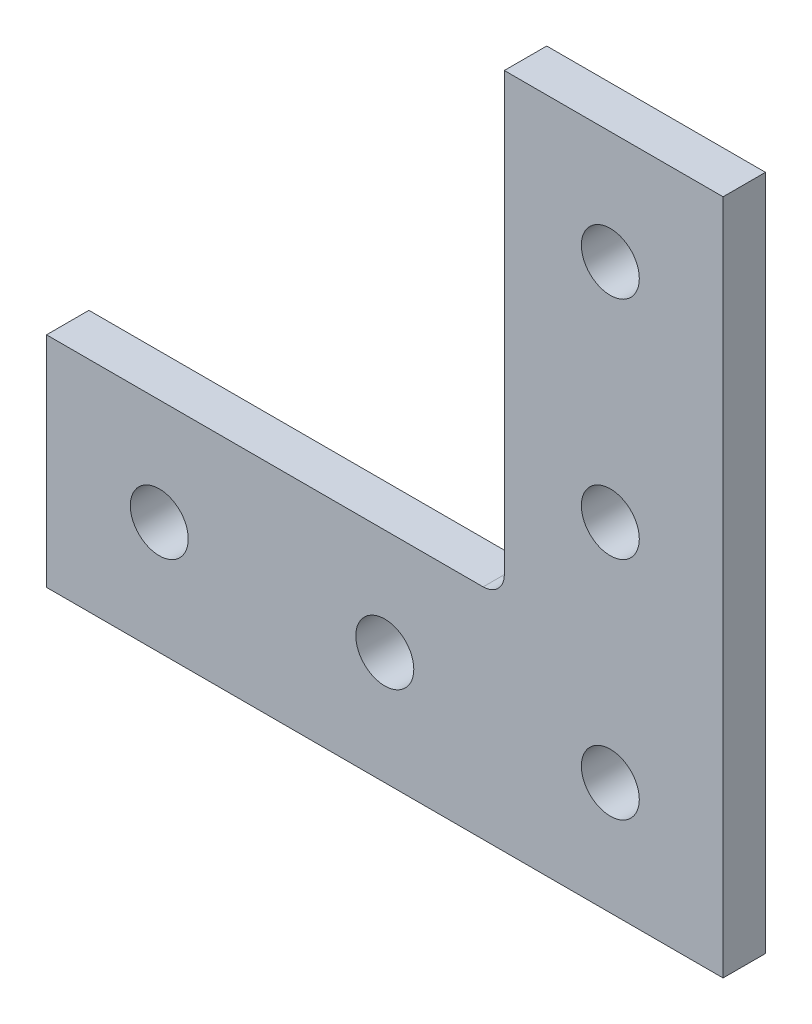
from build123d import *

# Parameters (mm, degrees)
SKETCH1_R           = 3.2639
BOSS_EXTRUDE1_DEPTH = 4.7752


with BuildPart() as part:
    # Sketch1 → Boss-Extrude1 (new body)
    with BuildSketch(Plane.XY):
        with BuildLine():
            Line((-76.2, 0), (0, 0))
            Line((0, 0), (0, 76.2))
            Line((0, 76.2), (-24.638, 76.2))
            Line((-24.638, 76.2), (-24.638, 27.0256))
            ThreePointArc((-24.638, 27.0256), (-25.337311849, 25.337311849), (-27.0256, 24.638))
            Line((-27.0256, 24.638), (-76.2, 24.638))
            Line((-76.2, 24.638), (-76.2, 0))
        make_face()
        with Locations((-12.7, 38.1)):
            Circle(SKETCH1_R, mode=Mode.SUBTRACT)
        with Locations((-12.7, 63.5)):
            Circle(SKETCH1_R, mode=Mode.SUBTRACT)
        with Locations((-12.7, 12.7)):
            Circle(SKETCH1_R, mode=Mode.SUBTRACT)
        with Locations((-38.1, 12.7)):
            Circle(SKETCH1_R, mode=Mode.SUBTRACT)
        with Locations((-63.5, 12.7)):
            Circle(SKETCH1_R, mode=Mode.SUBTRACT)
    extrude(amount=BOSS_EXTRUDE1_DEPTH)


solid = part.part
